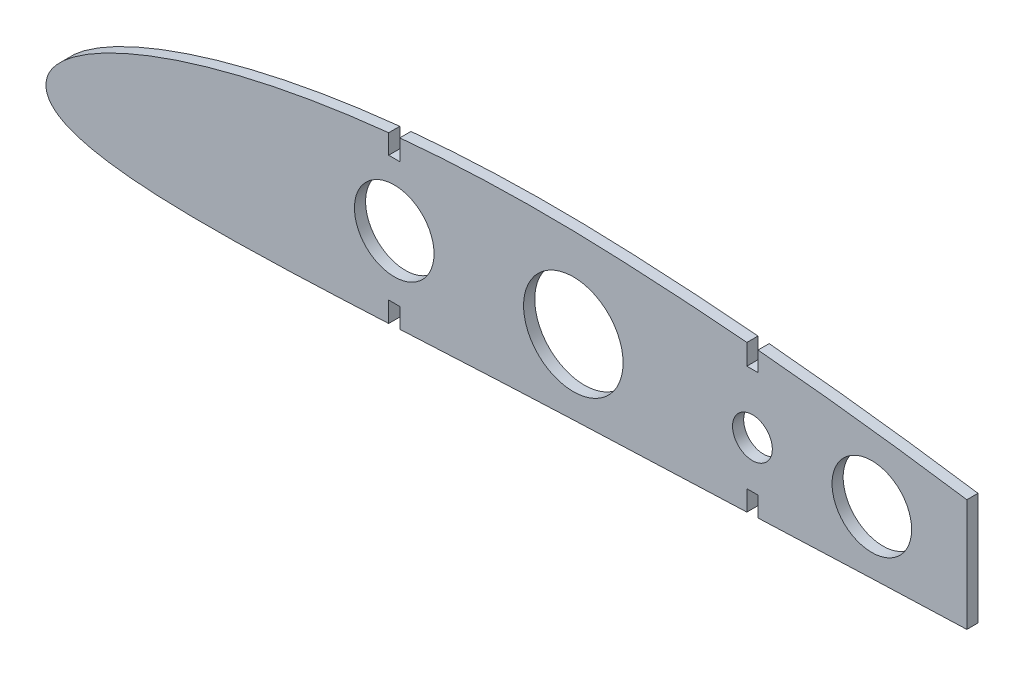
from build123d import *

# Parameters (mm, degrees)
SKETCH_2_R      = 10
SKETCH_2_R_2    = 5
SKETCH_2_R_3    = 12.5
EXTRUDE_1_DEPTH = 1.4


with BuildPart() as part:
    # Эскиз2 → Бобышка-Вытянуть1 (new body, symmetric)
    with BuildSketch(Plane.XY):
        with BuildLine():
            Line((86.1, 32.682283633), (86.1, 27.785621096))
            Line((86.1, 27.785621096), (88.9, 27.785621096))
            Line((88.9, 27.785621096), (88.9, 32.962973681))
            add(Edge.make_bspline(
                [(176.1, 32.045532515), (173.460642448, 32.274383054), (167.786299659, 32.738244602), (159.079993996, 33.354548335), (150.013824851, 33.880339702), (141.037533969, 34.297759375), (132.176453799, 34.561309726), (123.418285188, 34.636133951), (114.728660276, 34.522388831), (106.092728827, 34.217419352), (97.485414888, 33.712894632), (91.763569037, 33.237837821), (88.9, 32.962973681)],
                knots=[0.48932836, 0.48932836, 0.48932836, 0.48932836, 0.51130307, 0.536551515, 0.561723366, 0.586628867, 0.611085431, 0.6352512, 0.659272176, 0.683163753, 0.706922144, 0.730783121, 0.730783121, 0.730783121, 0.730783121], degree=3))
            Line((176.1, 32.045532515), (176.1, 26.882916451))
            Line((176.1, 26.882916451), (178.9, 26.882916451))
            Line((178.9, 26.882916451), (178.9, 31.797856127))
            add(Edge.make_bspline(
                [(231.376774993, 25.460683081), (228.623090859, 25.872976705), (222.81618615, 26.717098435), (213.950527179, 27.922839845), (204.785615162, 29.076995056), (195.623903708, 30.135946559), (186.99647265, 31.041402296), (181.421156727, 31.570451189), (178.9, 31.797856127)],
                knots=[0.335389042, 0.335389042, 0.335389042, 0.335389042, 0.358484538, 0.384061186, 0.409602822, 0.435103874, 0.460559416, 0.481556447, 0.481556447, 0.481556447, 0.481556447], degree=3))
            Line((231.376774993, 25.460683081), (231.376774993, -2.762108733))
            add(Edge.make_bspline(
                [(178.9, -4.758637273), (181.652979317, -4.646278606), (187.626173611, -4.403273739), (196.81461857, -4.035333009), (206.460819266, -3.659492142), (216.093643375, -3.297876981), (224.397462902, -3.000330699), (229.490633691, -2.825658562), (231.376774993, -2.762108733)],
                knots=[0.517634386, 0.517634386, 0.517634386, 0.517634386, 0.540928595, 0.568176028, 0.595379569, 0.622543445, 0.64967326, 0.665628529, 0.665628529, 0.665628529, 0.665628529], degree=3))
            Line((178.9, -4.758637273), (178.9, 0.224194977))
            Line((178.9, 0.224194977), (176.1, 0.224194977))
            Line((176.1, 0.224194977), (176.1, -4.873020948))
            add(Edge.make_bspline(
                [(88.9, -8.693267562), (89.617844041, -8.657365264), (93.544099689, -8.4603043), (100.675081793, -8.097607246), (110.279925807, -7.615552634), (119.854698054, -7.155331752), (129.404950626, -6.726934654), (138.957043666, -6.344774315), (148.536329767, -5.989584537), (158.156896352, -5.604325894), (167.348797605, -5.231176131), (173.335752744, -4.986028102), (176.1, -4.873020948)],
                knots=[0.263757046, 0.263757046, 0.263757046, 0.263757046, 0.269833583, 0.296993022, 0.324123272, 0.351139107, 0.378035509, 0.404946016, 0.431960837, 0.459078395, 0.4863474, 0.509737017, 0.509737017, 0.509737017, 0.509737017], degree=3))
            Line((88.9, -8.693267562), (88.9, -3.723116029))
            Line((88.9, -3.723116029), (86.1, -3.723116029))
            Line((86.1, -3.723116029), (86.1, -8.832579685))
            add(Edge.make_bspline(
                [(0.067165, 0.869995), (0.031799348, 0.52288612), (-0.038949105, -0.171499965), (0.109187697, -1.238208426), (0.489573911, -2.294373299), (1.140063589, -3.311096493), (2.048873093, -4.254985343), (3.207362223, -5.125399257), (4.62830025, -5.930091469), (6.349357867, -6.683143801), (8.441643964, -7.39506903), (11.016573701, -8.071443347), (14.236363949, -8.71040323), (18.305613464, -9.295466224), (23.419361508, -9.790139433), (29.665932935, -10.146283203), (36.959978182, -10.327294388), (45.07635799, -10.326759678), (53.756929463, -10.166011212), (62.800670475, -9.879297901), (72.081160335, -9.501034945), (79.871929674, -9.138172062), (84.562006059, -8.908655535), (86.1, -8.832579685)],
                knots=[0, 0, 0, 0, 0.002941446, 0.005884319, 0.00901613, 0.012364547, 0.016007934, 0.020036845, 0.024573728, 0.029783835, 0.03589701, 0.04324044, 0.052275965, 0.063634589, 0.077983176, 0.095698161, 0.116520086, 0.13966073, 0.16431217, 0.18991889, 0.216157201, 0.242837762, 0.255856498, 0.255856498, 0.255856498, 0.255856498], degree=3))
            add(Edge.make_bspline(
                [(86.1, 32.682283633), (84.251034658, 32.488999326), (79.618112888, 31.965003077), (72.248067764, 30.96669173), (64.042160436, 29.619190205), (55.994200632, 28.049519945), (48.157087779, 26.258842728), (40.614534945, 24.258661851), (33.496117772, 22.08061089), (26.978950376, 19.787977208), (21.250737748, 17.476669613), (16.436666106, 15.253855393), (12.543120617, 13.201408311), (9.465247652, 11.352044479), (7.047193647, 9.694493277), (5.140372907, 8.19592153), (3.628941572, 6.819827516), (2.433445936, 5.533634041), (1.497819162, 4.313324923), (0.800303575, 3.138270943), (0.302083458, 2.003099556), (0.143157814, 1.236538372), (0.067165, 0.869995)],
                knots=[0.738563451, 0.738563451, 0.738563451, 0.738563451, 0.7539832, 0.77723469, 0.800246382, 0.822950709, 0.845237155, 0.866915896, 0.887662335, 0.906968281, 0.924203157, 0.938878975, 0.950931611, 0.960693484, 0.968646729, 0.975232933, 0.980794744, 0.985583761, 0.989781539, 0.993521313, 0.996902113, 1, 1, 1, 1], degree=3))
        make_face()
        with Locations((87.5, 12.031252534)):
            Circle(SKETCH_2_R, mode=Mode.SUBTRACT)
        with Locations((177.5, 12.031252534)):
            Circle(SKETCH_2_R_2, mode=Mode.SUBTRACT)
        with Locations((132.5, 12.031252534)):
            Circle(SKETCH_2_R_3, mode=Mode.SUBTRACT)
        with Locations((207.5, 12.031252534)):
            Circle(SKETCH_2_R, mode=Mode.SUBTRACT)
    extrude(amount=EXTRUDE_1_DEPTH, both=True)


solid = part.part
